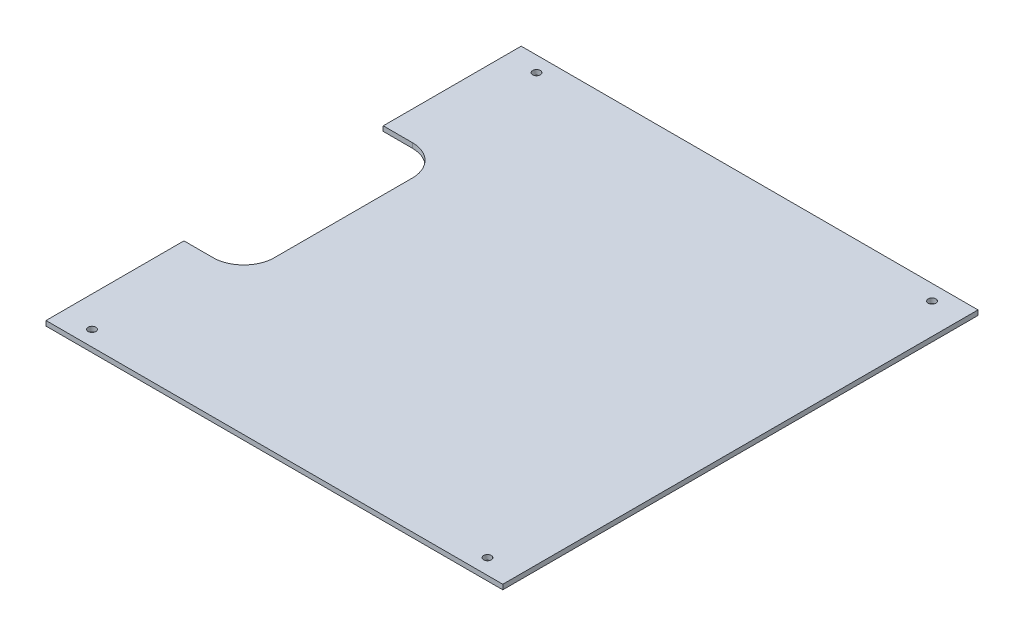
from build123d import *

# Parameters (mm, degrees)
BOSS_EXTRUDE1_DEPTH = 3.175
SKETCH3_R           = 2.5
CUT_EXTRUDE1_DEPTH  = 10


with BuildPart() as part:
    # Sketch2 → Boss-Extrude1 (new body)
    with BuildSketch(Plane(origin=(0, 0, 0), x_dir=(1, 0, 0), z_dir=(0, 1, 0))):
        with BuildLine():
            Line((21, 310), (21, 289))
            Line((21, 289), (21, 220))
            Line((21, 220), (40, 220))
            ThreePointArc((40, 220), (54.142135624, 214.142135624), (60, 200))
            Line((60, 200), (60, 110))
            ThreePointArc((60, 110), (54.142135624, 95.857864376), (40, 90))
            Line((40, 90), (21, 90))
            Line((21, 90), (21, 21))
            Line((21, 21), (21, 0))
            Line((21, 0), (319, 0))
            Line((319, 0), (319, 21))
            Line((319, 21), (319, 289))
            Line((319, 289), (319, 310))
            Line((319, 310), (21, 310))
        make_face()
    extrude(amount=BOSS_EXTRUDE1_DEPTH)

    # Sketch3 → Cut-Extrude1 (cut)
    with BuildSketch(Plane(origin=(0, 3.175, 0), x_dir=(1, 0, 0), z_dir=(0, 1, 0))):
        with Locations((41, 300)):
            Circle(SKETCH3_R)
        with Locations((10, 269)):
            Circle(SKETCH3_R)
        with Locations((299, 300)):
            Circle(SKETCH3_R)
        with Locations((330, 269)):
            Circle(SKETCH3_R)
        with Locations((330, 41)):
            Circle(SKETCH3_R)
        with Locations((299, 10)):
            Circle(SKETCH3_R)
        with Locations((41, 10)):
            Circle(SKETCH3_R)
        with Locations((10, 41)):
            Circle(SKETCH3_R)
    extrude(amount=-CUT_EXTRUDE1_DEPTH, mode=Mode.SUBTRACT)


solid = part.part
